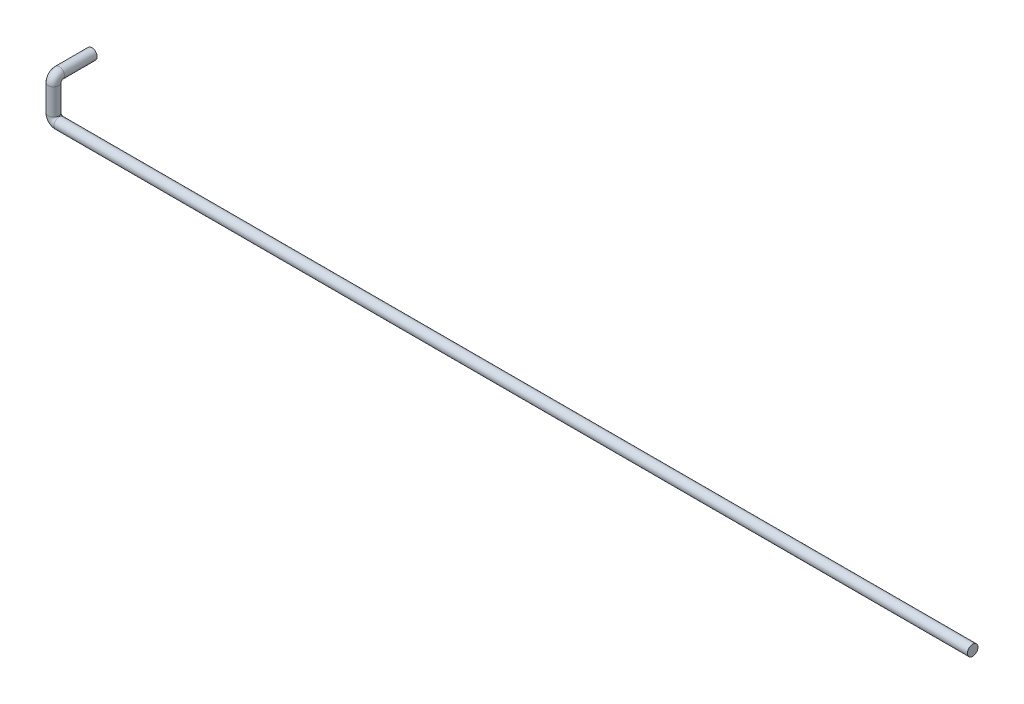
from build123d import *

# Parameters (mm, degrees)
CROQUIS1_R = 13.7


with BuildPart() as part:
    # Barrer1: sweep along a curve in space
    with BuildLine() as barrer1_path:
        Line((0, 0, 0), (-2374, 0, 0))
        ThreePointArc((-2374, 0, 0), (-2384.606601718, 4.393398282, 0), (-2389, 15, 0))
        Line((-2389, 15, 0), (-2389, 83, 0))
        ThreePointArc((-2389, 83, 0), (-2389, 93.606601718, -4.393398282), (-2389, 98, -15))
        Line((-2389, 98, -15), (-2389, 98, -100))
    # Croquis1 → Barrer1 (sweep)
    with BuildSketch(Plane(origin=(0, 0, 0), x_dir=(0, 0, -1), z_dir=(1, 0, 0))):
        Circle(CROQUIS1_R)
    sweep(path=barrer1_path.line)


solid = part.part
